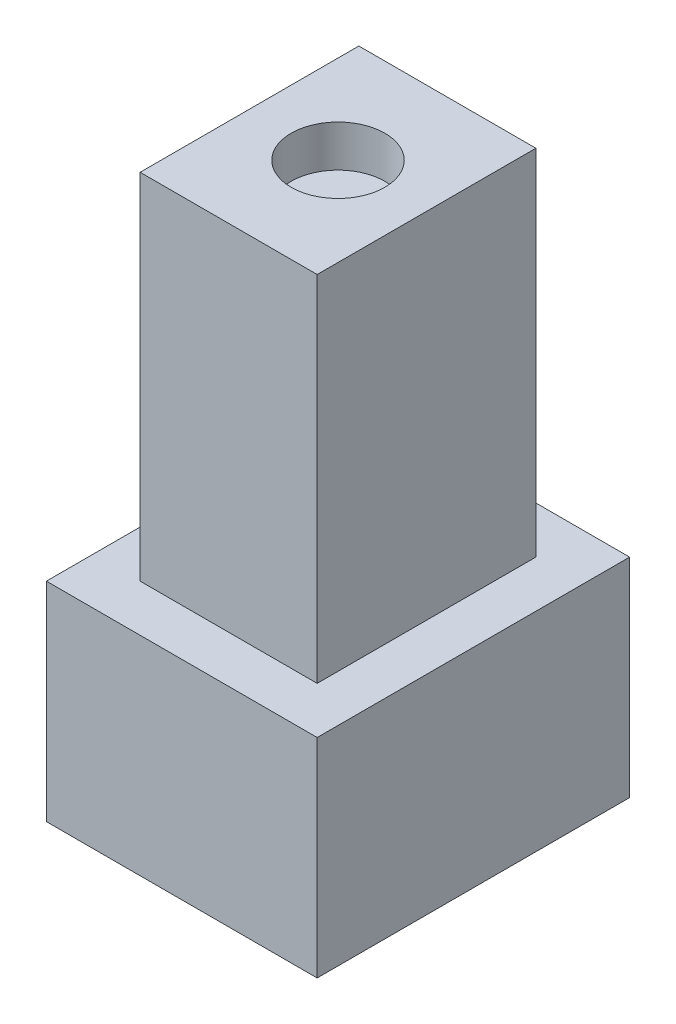
from build123d import *

# Parameters (mm, degrees)
SKETCH1_W           = 13
SKETCH1_H           = 15
BOSS_EXTRUDE1_DEPTH = 10
SKETCH2_W           = 8.5
SKETCH2_H           = 10.5
BOSS_EXTRUDE2_DEPTH = 17
SKETCH3_R           = 2.25
CUT_EXTRUDE1_DEPTH  = 2


with BuildPart() as part:
    # Sketch1 → Boss-Extrude1 (new body)
    with BuildSketch(Plane(origin=(0, 0, 0), x_dir=(1, 0, 0), z_dir=(0, 1, 0))):
        with Locations((6.5, 7.5)):
            Rectangle(SKETCH1_W, SKETCH1_H)
    extrude(amount=BOSS_EXTRUDE1_DEPTH)

    # Sketch2 → Boss-Extrude2 (add)
    with BuildSketch(Plane(origin=(0, 10, 0), x_dir=(1, 0, 0), z_dir=(0, 1, 0))):
        with Locations((6.5, 7.5)):
            Rectangle(SKETCH2_W, SKETCH2_H)
    extrude(amount=BOSS_EXTRUDE2_DEPTH)

    # Sketch3 → Cut-Extrude1 (cut)
    with BuildSketch(Plane(origin=(0, 27, 0), x_dir=(1, 0, 0), z_dir=(0, 1, 0))):
        with Locations((6.5, 7.5)):
            Circle(SKETCH3_R)
    extrude(amount=-CUT_EXTRUDE1_DEPTH, mode=Mode.SUBTRACT)


solid = part.part
